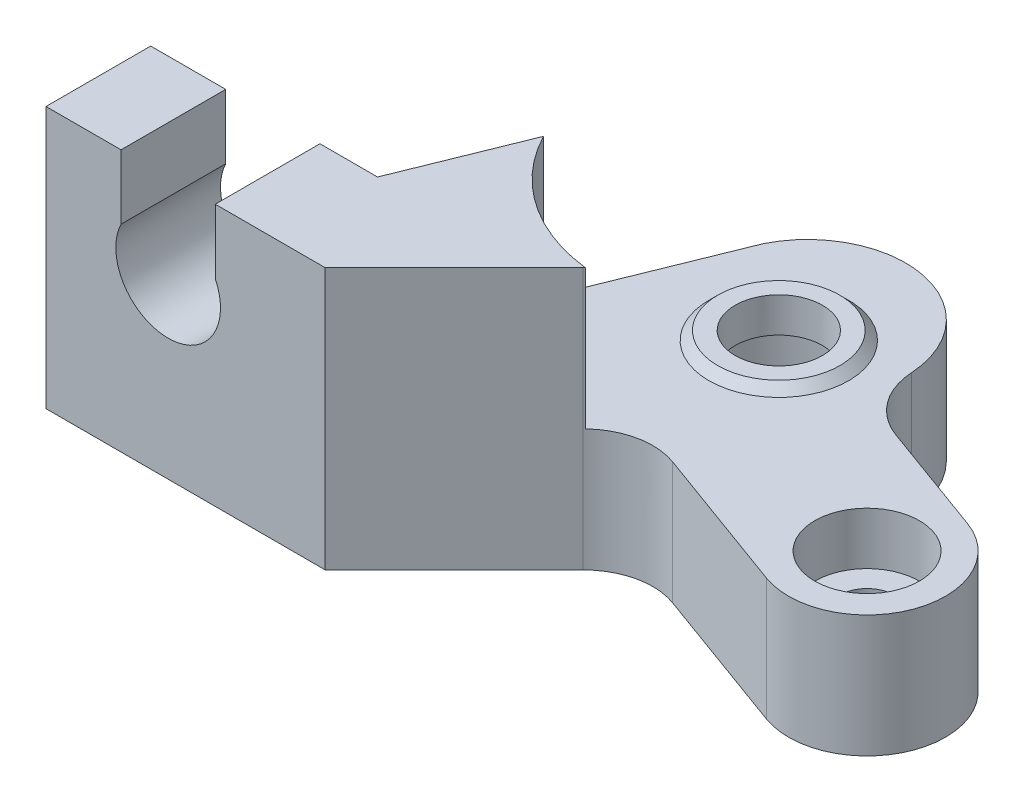
from build123d import *

# Parameters (mm, degrees)
BOSS_EXTRUDE2_DEPTH = 15
CUT_EXTRUDE2_DEPTH  = 8
SKETCH5_R           = 4
BOSS_EXTRUDE3_DEPTH = 0.5
BOSS_EXTRUDE3_TAPER = 45
SKETCH6_R           = 2.5
CUT_EXTRUDE3_DEPTH  = 2
SKETCH7_R           = 4.5
CUT_EXTRUDE4_DEPTH  = 5.5
CUT_EXTRUDE5_DEPTH  = 15
SKETCH9_R           = 3
CUT_EXTRUDE6_DEPTH  = 3
SKETCH10_R          = 1.6
CUT_EXTRUDE7_DEPTH  = 4


with BuildPart() as part:
    # Sketch1 → Boss-Extrude2 (new body)
    with BuildSketch(Plane(origin=(0, 0, 0), x_dir=(1, 0, 0), z_dir=(0, 1, 0))):
        with BuildLine():
            Line((0, 0), (16, 0))
            Line((16, 0), (23.390481349, 7.390481349))
            ThreePointArc((23.390481349, 7.390481349), (25.353150018, 8.467238253), (27.586989047, 8.320824708))
            Line((27.586989047, 8.320824708), (36.044222635, 5.242643418))
            ThreePointArc((36.044222635, 5.242643418), (41.811930073, 7.932169566), (39.122403924, 13.699877005))
            Line((39.122403924, 13.699877005), (32.638524841, 16.059815994))
            ThreePointArc((32.638524841, 16.059815994), (30.799841796, 17.427631209), (30.013713531, 19.580228745))
            ThreePointArc((30.013713531, 19.580228745), (25.528138256, 24.7554842), (19.368312088, 21.762125528))
            Line((19.368312088, 21.762125528), (13, 6))
            Line((13, 6), (0, 6))
            Line((0, 6), (0, 0))
        make_face()
    extrude(amount=BOSS_EXTRUDE2_DEPTH)

    # Sketch4 → Cut-Extrude2 (cut)
    with BuildSketch(Plane(origin=(0, 15, 0), x_dir=(1, 0, 0), z_dir=(0, 1, 0))):
        with BuildLine():
            Line((27.527056586, 7.82026535), (39.563282013, 1.837894564))
            Line((39.563282013, 1.837894564), (45.039561208, 12.855889478))
            Line((45.039561208, 12.855889478), (34.588386796, 18.050441613))
            ThreePointArc((34.588386796, 18.050441613), (16.380660644, 23.066124632), (27.527056586, 7.82026535))
        make_face()
    extrude(amount=-CUT_EXTRUDE2_DEPTH, mode=Mode.SUBTRACT)

    # Sketch5 → Boss-Extrude3 (add)
    with BuildSketch(Plane(origin=(0, 7, 0), x_dir=(1, 0, 0), z_dir=(0, 1, 0))):
        with Locations((24.610518338, 17.385504743)):
            Circle(SKETCH5_R)
    extrude(amount=BOSS_EXTRUDE3_DEPTH, taper=BOSS_EXTRUDE3_TAPER)

    # Sketch6 → Cut-Extrude3 (cut)
    with BuildSketch(Plane(origin=(0, 7.5, 0), x_dir=(1, 0, 0), z_dir=(0, 1, 0))):
        with Locations((24.610518338, 17.385504743)):
            Circle(SKETCH6_R)
    extrude(amount=-CUT_EXTRUDE3_DEPTH, mode=Mode.SUBTRACT)

    # Sketch7 → Cut-Extrude4 (cut)
    with BuildSketch(Plane.XZ):
        with Locations((24.610518338, -17.385504743)):
            Circle(SKETCH7_R)
    extrude(amount=-CUT_EXTRUDE4_DEPTH, mode=Mode.SUBTRACT)

    # Sketch8 → Cut-Extrude5 (cut)
    with BuildSketch(Plane.XY):
        with BuildLine():
            Line((4.3, 11.307669683), (4.3, 15))
            Line((4.3, 15), (9.7, 15))
            Line((9.7, 15), (9.7, 11.307669683))
            ThreePointArc((9.7, 11.307669683), (7, 7), (4.3, 11.307669683))
        make_face()
    extrude(amount=-CUT_EXTRUDE5_DEPTH, mode=Mode.SUBTRACT)

    # Sketch9 → Cut-Extrude6 (cut)
    with BuildSketch(Plane(origin=(0, 7, 0), x_dir=(1, 0, 0), z_dir=(0, 1, 0))):
        with Locations((37.583313279, 9.471260211)):
            Circle(SKETCH9_R)
    extrude(amount=-CUT_EXTRUDE6_DEPTH, mode=Mode.SUBTRACT)

    # Sketch10 → Cut-Extrude7 (cut)
    with BuildSketch(Plane(origin=(0, 4, 0), x_dir=(1, 0, 0), z_dir=(0, 1, 0))):
        with Locations((37.583313279, 9.471260211)):
            Circle(SKETCH10_R)
    extrude(amount=-CUT_EXTRUDE7_DEPTH, mode=Mode.SUBTRACT)


solid = part.part
